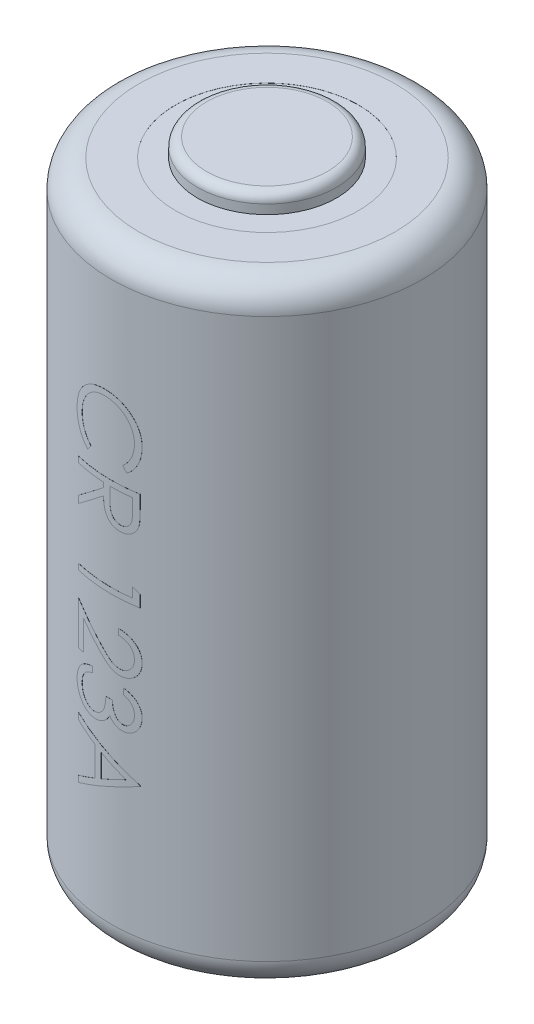
from build123d import *

# Parameters (mm, degrees)
SKIZZE1_R                            = 8.5
AUFSATZ_LINEAR_AUSTRAGEN1_DEPTH      = 33.5
SKIZZE2_R                            = 3.799988553
AUFSATZ_LINEAR_AUSTRAGEN2_DEPTH      = 1
VERRUNDUNG1_R                        = 1.5
VERRUNDUNG2_R                        = 0.5
SKIZZE3_R                            = 5
SKIZZE3_R_2                          = 3.799988553
SCHNITT_LINEAR_AUSTRAGEN1_DEPTH      = 0.005
AUFSATZ_LINEAR_AUSTRAGEN3_REACH      = 38.534
AUFSATZ_LINEAR_AUSTRAGEN3_END_RADIUS = 8.505


with BuildPart() as part:
    # Skizze1 → Aufsatz-Linear austragen1 (new body)
    with BuildSketch(Plane(origin=(0, 0, 0), x_dir=(1, 0, 0), z_dir=(0, 1, 0))):
        with Locations(Location((0, 0, 0), (0, 0, 270))):
            Circle(SKIZZE1_R)
    extrude(amount=AUFSATZ_LINEAR_AUSTRAGEN1_DEPTH)

    # Skizze2 → Aufsatz-Linear austragen2 (add)
    with BuildSketch(Plane(origin=(0, 33.5, 0), x_dir=(1, 0, 0), z_dir=(0, 1, 0))):
        with Locations(Location((0, 0, 0), (0, 0, 270))):
            Circle(SKIZZE2_R)
    extrude(amount=AUFSATZ_LINEAR_AUSTRAGEN2_DEPTH)

    # Verrundung1
    verrundung1_edges = [part.edges().sort_by_distance(p)[0] for p in [
        (0, 0, -8.5),
        (0, 33.5, -8.5),
    ]]
    fillet(verrundung1_edges, radius=VERRUNDUNG1_R)

    # Verrundung2
    verrundung2_edges = [part.edges().sort_by_distance(p)[0] for p in [
        (0, 34.5, -3.799988553),
    ]]
    fillet(verrundung2_edges, radius=VERRUNDUNG2_R)

    # Skizze3 → Schnitt-Linear austragen1 (cut)
    with BuildSketch(Plane(origin=(0, 33.5, 0), x_dir=(1, 0, 0), z_dir=(0, 1, 0))):
        with Locations(Location((0, 0, 0), (0, 0, 270))):
            Circle(SKIZZE3_R)
        with Locations(Location((0, 0, 0), (0, 0, 270))):
            Circle(SKIZZE3_R_2, mode=Mode.SUBTRACT)
    extrude(amount=-SCHNITT_LINEAR_AUSTRAGEN1_DEPTH, mode=Mode.SUBTRACT)

    # Aufsatz-Linear austragen3: up to this cylinder (the profile starts inside it)
    aufsatz_linear_austragen3_end = Plane(origin=(0, 15.6548225, 0), z_dir=(0, -1, 0)) * Cylinder(AUFSATZ_LINEAR_AUSTRAGEN3_END_RADIUS, 110.548259, mode=Mode.PRIVATE)
    # Skizze4 → Aufsatz-Linear austragen3 (add, up to the surface)
    with BuildSketch(Plane.XY, mode=Mode.PRIVATE) as aufsatz_linear_austragen3_sk1:
        with BuildLine():
            Line((0.812137548, 23.222042681), (0.60180101, 23.496882424))
            add(Edge.make_bspline(
                [(0.60180101, 23.496882424), (0.62516698, 23.516488313), (0.671583895, 23.555435759), (0.73676344, 23.618094962), (0.797828701, 23.683396605), (0.855070581, 23.751315726), (0.906487347, 23.823074845), (0.95475845, 23.896935644), (0.998026188, 23.974133689), (1.050489174, 24.080885424), (1.105235329, 24.220533272), (1.15113856, 24.396328111), (1.180359736, 24.57983921), (1.183524577, 24.705036809), (1.185134343, 24.76871736)],
                knots=[0, 0, 0, 0, 0.757959112, 1.505699292, 2.245454638, 2.979532153, 3.711538275, 4.438200793, 5.171680507, 5.909471876, 7.393775596, 8.890124382, 10.418191784, 12, 12, 12, 12], degree=3))
            add(Edge.make_bspline(
                [(1.185134343, 24.76871736), (1.184728558, 24.803800233), (1.183920753, 24.873640377), (1.173338528, 24.977295144), (1.158293792, 25.079210677), (1.136513413, 25.179007988), (1.108157335, 25.276488925), (1.074903224, 25.372395725), (1.033521858, 25.465598861), (0.987821664, 25.55722001), (0.936188844, 25.644995169), (0.87988858, 25.728063146), (0.819473451, 25.806044444), (0.755099407, 25.87915515), (0.685966407, 25.946593449), (0.612887721, 26.009440138), (0.534983754, 26.066562574), (0.453715531, 26.119364439), (0.368963602, 26.166348655), (0.281261128, 26.206921801), (0.190943428, 26.24169636), (0.097825479, 26.269467711), (0.002273724, 26.291372711), (-0.09591462, 26.30650568), (-0.196548965, 26.316992708), (-0.264758187, 26.317793081), (-0.299140497, 26.318196527)],
                knots=[0, 0, 0, 0, 1.055000685, 2.100209969, 3.131349012, 4.153242145, 5.170189196, 6.184191144, 7.204341339, 8.235672124, 9.263040994, 10.265373269, 11.252624173, 12.22887325, 13.193405896, 14.155809299, 15.126090485, 16.097288279, 17.069732292, 18.038585918, 19.002221264, 19.978698174, 20.959418239, 21.948869816, 22.966084182, 24, 24, 24, 24], degree=3))
            add(Edge.make_bspline(
                [(-0.299140497, 26.318196527), (-0.350871816, 26.316934708), (-0.452439401, 26.314457293), (-0.601210012, 26.292408959), (-0.743730686, 26.258903868), (-0.879110528, 26.208688291), (-1.009018886, 26.146769241), (-1.131257739, 26.068528629), (-1.247674304, 25.977912092), (-1.355517252, 25.873637672), (-1.454030977, 25.759231856), (-1.540781558, 25.636483945), (-1.613096441, 25.505699657), (-1.673272387, 25.368323027), (-1.719529115, 25.223296913), (-1.752093239, 25.07088211), (-1.773335419, 24.911410115), (-1.775369107, 24.802440715), (-1.776404118, 24.746982584)],
                knots=[0, 0, 0, 0, 1.029171465, 2.020641659, 2.987623507, 3.938342917, 4.889210282, 5.84687017, 6.821220943, 7.821438502, 8.827599549, 9.822697543, 10.807740252, 11.797342354, 12.80366471, 13.83203677, 14.896651826, 16, 16, 16, 16], degree=3))
            add(Edge.make_bspline(
                [(-1.776404118, 24.746982584), (-1.774715339, 24.685879895), (-1.771391416, 24.565615187), (-1.743232167, 24.38924716), (-1.697574249, 24.220411395), (-1.633676327, 24.059098808), (-1.550611039, 23.905764162), (-1.449913161, 23.760167502), (-1.330624829, 23.622185931), (-1.2395417, 23.539214649), (-1.193070785, 23.496882424)],
                knots=[0, 0, 0, 0, 1.028121516, 2.023589091, 2.998037872, 3.967518031, 4.937445131, 5.927275754, 6.942489185, 8, 8, 8, 8], degree=3))
            Line((-1.193070785, 23.496882424), (-1.401303958, 23.222042681))
            add(Edge.make_bspline(
                [(-1.401303958, 23.222042681), (-1.429842459, 23.244160761), (-1.486782762, 23.288290978), (-1.567053749, 23.35974943), (-1.642560487, 23.435025101), (-1.712678052, 23.514686863), (-1.778870221, 23.597781962), (-1.838917955, 23.685774076), (-1.894650403, 23.77714341), (-1.945006838, 23.87242193), (-1.990156908, 23.971296824), (-2.028273845, 24.073665195), (-2.061580939, 24.178659772), (-2.088801157, 24.286333431), (-2.110080876, 24.397045881), (-2.12429818, 24.510417263), (-2.134040734, 24.626686893), (-2.134928563, 24.705128347), (-2.135378477, 24.744879219)],
                knots=[0, 0, 0, 0, 0.986756325, 1.968786143, 2.935506311, 3.899499537, 4.868307269, 5.8376204, 6.809456583, 7.792545619, 8.781780509, 9.778496008, 10.776623214, 11.79151764, 12.812666265, 13.856269958, 14.913646641, 16, 16, 16, 16], degree=3))
            add(Edge.make_bspline(
                [(-2.135378477, 24.744879219), (-2.135116485, 24.782522886), (-2.134598427, 24.856958576), (-2.12620626, 24.966857328), (-2.114756523, 25.073846909), (-2.097516392, 25.177621535), (-2.077172051, 25.27874751), (-2.049900795, 25.376308094), (-2.019351628, 25.471263304), (-1.983446642, 25.563231645), (-1.942930459, 25.652291345), (-1.8971389, 25.738155156), (-1.846457035, 25.820783589), (-1.792002025, 25.90098901), (-1.732024723, 25.977586593), (-1.667358089, 26.051240119), (-1.598220078, 26.122362595), (-1.548365225, 26.16636528), (-1.52329915, 26.188488995)],
                knots=[0, 0, 0, 0, 1.114604814, 2.203992996, 3.262667896, 4.300477797, 5.318619304, 6.316056647, 7.298880507, 8.271930387, 9.238335007, 10.195173496, 11.151986948, 12.108099108, 13.064862484, 14.031167946, 15.010108607, 16, 16, 16, 16], degree=3))
            add(Edge.make_bspline(
                [(-1.52329915, 26.188488995), (-1.479757961, 26.223924638), (-1.393201251, 26.294368115), (-1.25291527, 26.384493799), (-1.106447061, 26.461641354), (-0.953027132, 26.524017275), (-0.792999745, 26.572780008), (-0.62628423, 26.606561203), (-0.453036288, 26.628512807), (-0.3351995, 26.631023096), (-0.275302356, 26.632299091)],
                knots=[0, 0, 0, 0, 0.994628077, 1.977248131, 2.950237994, 3.925870899, 4.908910175, 5.911660606, 6.938484602, 8, 8, 8, 8], degree=3))
            add(Edge.make_bspline(
                [(-0.275302356, 26.632299091), (-0.212349536, 26.630736941), (-0.088493793, 26.62766351), (0.093317753, 26.601766994), (0.267255421, 26.559602465), (0.43398848, 26.501541626), (0.592562947, 26.424943857), (0.74364855, 26.332216062), (0.887121922, 26.222452515), (1.021148744, 26.097031743), (1.143684832, 25.95945716), (1.251491889, 25.812140241), (1.34120918, 25.655357794), (1.416205403, 25.490840076), (1.47384985, 25.317354359), (1.514203041, 25.135270999), (1.539320156, 24.944932082), (1.542495364, 24.815069657), (1.544108702, 24.74908595)],
                knots=[0, 0, 0, 0, 1.032901378, 2.032168977, 3.007206631, 3.966850309, 4.924221947, 5.891988639, 6.871730993, 7.884084801, 8.900290346, 9.89161143, 10.874607481, 11.860025555, 12.854717796, 13.869097222, 14.917278314, 16, 16, 16, 16], degree=3))
            add(Edge.make_bspline(
                [(1.544108702, 24.74908595), (1.543626924, 24.708871399), (1.542673293, 24.629270746), (1.533361929, 24.511519236), (1.517867523, 24.39687271), (1.49663914, 24.285053911), (1.470620258, 24.175657363), (1.436559531, 24.06980539), (1.397006677, 23.966921591), (1.352614272, 23.86692891), (1.301863581, 23.770915237), (1.246743012, 23.678898047), (1.185980195, 23.591987357), (1.121583953, 23.508548372), (1.051145443, 23.430459568), (0.97695855, 23.355490747), (0.896821888, 23.286231616), (0.840417335, 23.24347816), (0.812137548, 23.222042681)],
                knots=[0, 0, 0, 0, 1.096705196, 2.170817488, 3.219277236, 4.250701065, 5.274195539, 6.284202015, 7.28098643, 8.279664616, 9.266225751, 10.241373748, 11.203306326, 12.157093976, 13.114198862, 14.069774147, 15.032234603, 16, 16, 16, 16], degree=3))
        make_face()
    aufsatz_linear_austragen3_tool1 = extrude(aufsatz_linear_austragen3_sk1.sketch, amount=AUFSATZ_LINEAR_AUSTRAGEN3_REACH, mode=Mode.PRIVATE) & aufsatz_linear_austragen3_end
    add(aufsatz_linear_austragen3_tool1.solids().sort_by_distance((0.746809, 23.389952, 0))[0])
    # Skizze4 → Aufsatz-Linear austragen3 (add, up to the surface)
    with BuildSketch(Plane.XY, mode=Mode.PRIVATE) as aufsatz_linear_austragen3_sk2:
        with BuildLine():
            Line((1.454365112, 22.504093963), (1.454365112, 21.80367329))
            add(Edge.make_bspline(
                [(1.454365112, 21.80367329), (1.454209526, 21.756932161), (1.453910784, 21.667184017), (1.452245021, 21.538610746), (1.447470666, 21.421783649), (1.443362082, 21.31676381), (1.435870141, 21.223553155), (1.428709494, 21.141865864), (1.419335833, 21.072078167), (1.41063041, 21.029832315), (1.40668883, 21.01070454)],
                knots=[0, 0, 0, 0, 1.410062039, 2.707475311, 3.878576406, 4.937260626, 5.877586885, 6.699081471, 7.410979367, 8, 8, 8, 8], degree=3))
            add(Edge.make_bspline(
                [(1.40668883, 21.01070454), (1.400362783, 20.985097464), (1.387845639, 20.934429582), (1.361375626, 20.86148606), (1.330794417, 20.791947595), (1.294596859, 20.726075144), (1.253414315, 20.663862597), (1.207006171, 20.605403103), (1.155136087, 20.551030892), (1.099128607, 20.500327595), (1.038495049, 20.454366688), (0.97411868, 20.414593537), (0.906402136, 20.380535988), (0.835109603, 20.353346822), (0.760843742, 20.331473971), (0.682956073, 20.316046319), (0.601794786, 20.306795522), (0.54643692, 20.305853612), (0.518367516, 20.305376014)],
                knots=[0, 0, 0, 0, 1.02737288, 2.032829108, 3.019628684, 3.985738875, 4.958353778, 5.924249254, 6.890702889, 7.883913451, 8.865824512, 9.85161466, 10.829249435, 11.81541824, 12.821369441, 13.843154991, 14.906364023, 16, 16, 16, 16], degree=3))
            add(Edge.make_bspline(
                [(0.518367516, 20.305376014), (0.471732358, 20.306844974), (0.380735085, 20.309711295), (0.248674954, 20.336436932), (0.125482898, 20.380211504), (0.011330359, 20.440541967), (-0.091617661, 20.517334891), (-0.181734433, 20.609622523), (-0.257842153, 20.716933557), (-0.310058757, 20.817302112), (-0.343657158, 20.906004496), (-0.36741579, 20.979244166), (-0.385462767, 21.05919693), (-0.401864947, 21.144715744), (-0.414381128, 21.236461164), (-0.423269996, 21.334248438), (-0.428985605, 21.438322137), (-0.42982068, 21.509661899), (-0.430250272, 21.546361591)],
                knots=[0, 0, 0, 0, 1.260402266, 2.459371274, 3.627181936, 4.786749125, 5.93865593, 7.087644312, 8.261344208, 9.485713728, 10.136162886, 10.825977872, 11.566646758, 12.35154167, 13.181268117, 14.0701832, 15.007234106, 16, 16, 16, 16], degree=3))
            Line((-0.430250272, 21.546361591), (-2.045634888, 20.260504219))
            Line((-2.045634888, 20.260504219), (-2.045634888, 20.648925693))
            Line((-2.045634888, 20.648925693), (-0.430250272, 21.934783065))
            Line((-0.430250272, 21.934783065), (-0.430250272, 22.189991399))
            Line((-0.430250272, 22.189991399), (-2.045634888, 22.189991399))
            Line((-2.045634888, 22.189991399), (-2.045634888, 22.504093963))
            Line((-2.045634888, 22.504093963), (1.454365112, 22.504093963))
        make_face()
        with BuildLine():
            Line((1.095390753, 22.189991399), (-0.071275913, 22.189991399))
            Line((-0.071275913, 22.189991399), (-0.076183766, 21.549166078))
            add(Edge.make_bspline(
                [(-0.076183766, 21.549166078), (-0.076197002, 21.519246039), (-0.076222659, 21.461252482), (-0.072228884, 21.377351816), (-0.067685561, 21.29923171), (-0.06073623, 21.227190939), (-0.05178011, 21.161197426), (-0.040577283, 21.101283808), (-0.027524707, 21.047353424), (-0.007325244, 20.984452072), (0.024695395, 20.914234557), (0.071203548, 20.837828514), (0.130079173, 20.77298334), (0.196332539, 20.717074233), (0.270674926, 20.67400998), (0.349806555, 20.64266676), (0.433044259, 20.622997142), (0.490216103, 20.620658703), (0.519068638, 20.619478578)],
                knots=[0, 0, 0, 0, 1.14660753, 2.222451964, 3.218720504, 4.145691244, 4.995719623, 5.770487122, 6.480909919, 7.121111896, 8.299844659, 9.430703709, 10.534634535, 11.641396424, 12.741395289, 13.810956493, 14.895269934, 16, 16, 16, 16], degree=3))
            add(Edge.make_bspline(
                [(0.519068638, 20.619478578), (0.547223017, 20.62066233), (0.603014723, 20.623008096), (0.68446816, 20.64270487), (0.761895021, 20.674512282), (0.8338195, 20.719113634), (0.899651492, 20.773007527), (0.955200409, 20.837014539), (1.00171939, 20.907911198), (1.031229533, 20.97422142), (1.049358083, 21.033449576), (1.062099247, 21.084881682), (1.072422096, 21.143216452), (1.080447915, 21.208314084), (1.087670236, 21.280056805), (1.092352997, 21.358641061), (1.095183259, 21.443976103), (1.095319979, 21.503123286), (1.095390753, 21.533741399)],
                knots=[0, 0, 0, 0, 1.100801541, 2.181386982, 3.260112282, 4.364594493, 5.481957178, 6.577424609, 7.668452592, 8.790448866, 9.403819393, 10.091598921, 10.863153553, 11.720938239, 12.658472417, 13.685008818, 14.801622349, 16, 16, 16, 16], degree=3))
            Line((1.095390753, 21.533741399), (1.095390753, 22.189991399))
        make_face(mode=Mode.SUBTRACT)
    aufsatz_linear_austragen3_tool2 = extrude(aufsatz_linear_austragen3_sk2.sketch, amount=AUFSATZ_LINEAR_AUSTRAGEN3_REACH, mode=Mode.PRIVATE) & aufsatz_linear_austragen3_end
    add(aufsatz_linear_austragen3_tool2.solids().sort_by_distance((-0.10468, 21.567098, 0))[0])
    # Skizze4 → Aufsatz-Linear austragen3 (add, up to the surface)
    with BuildSketch(Plane.XY, mode=Mode.PRIVATE) as aufsatz_linear_austragen3_sk3:
        Polygon((1.454365112, 17.766613995), (1.454365112, 17.119478578), (-2.045634888, 17.119478578), (-2.045634888, 17.433581142), (1.095390753, 17.433581142), (1.095390753, 17.972042681), align=None)
    aufsatz_linear_austragen3_tool3 = extrude(aufsatz_linear_austragen3_sk3.sketch, amount=AUFSATZ_LINEAR_AUSTRAGEN3_REACH, mode=Mode.PRIVATE) & aufsatz_linear_austragen3_end
    add(aufsatz_linear_austragen3_tool3.solids().sort_by_distance((-0.101766, 17.323734, 0))[0])
    # Skizze4 → Aufsatz-Linear austragen3 (add, up to the surface)
    with BuildSketch(Plane.XY, mode=Mode.PRIVATE) as aufsatz_linear_austragen3_sk4:
        with BuildLine():
            Line((0.377442036, 15.369478578), (0.377442036, 15.683581142))
            add(Edge.make_bspline(
                [(0.377442036, 15.683581142), (0.419113129, 15.681534338), (0.500954047, 15.677514468), (0.620275047, 15.658681248), (0.734340365, 15.631758216), (0.842172101, 15.593601998), (0.945058395, 15.546482403), (1.041633037, 15.488794384), (1.132854518, 15.421767754), (1.216995714, 15.345525477), (1.293911286, 15.26279558), (1.361034701, 15.174073744), (1.417098552, 15.080271861), (1.464221512, 14.982203528), (1.499550068, 14.878734557), (1.52577479, 14.770853994), (1.541550295, 14.658074232), (1.543246197, 14.581234296), (1.544108702, 14.54215486)],
                knots=[0, 0, 0, 0, 1.100776268, 2.161895295, 3.184016182, 4.190939212, 5.176500551, 6.166955529, 7.155448256, 8.160289653, 9.16017456, 10.133824356, 11.091467644, 12.04088621, 13.000931625, 13.972173743, 14.968683325, 16, 16, 16, 16], degree=3))
            add(Edge.make_bspline(
                [(1.544108702, 14.54215486), (1.543210246, 14.503776786), (1.541444811, 14.428365241), (1.526283782, 14.318303227), (1.50253819, 14.213525932), (1.469222774, 14.114238166), (1.424438346, 14.021232101), (1.370640808, 13.933809057), (1.308420976, 13.850928246), (1.235167163, 13.776321462), (1.156964778, 13.707813383), (1.073476875, 13.648711128), (0.987247589, 13.598097965), (0.897619387, 13.555910285), (0.803748359, 13.524854146), (0.707001156, 13.501275938), (0.606376345, 13.487948524), (0.53826979, 13.4859031), (0.503643959, 13.484863193)],
                knots=[0, 0, 0, 0, 1.111607364, 2.184268762, 3.212621178, 4.221274766, 5.211760367, 6.196651075, 7.1921475, 8.207485113, 9.220403448, 10.201281604, 11.166441695, 12.114753415, 13.065576456, 14.026450734, 14.996634279, 16, 16, 16, 16], degree=3))
            add(Edge.make_bspline(
                [(0.503643959, 13.484863193), (0.454896124, 13.486556456), (0.35825591, 13.489913268), (0.216241048, 13.518627644), (0.078647629, 13.563474155), (-0.032089674, 13.617471512), (-0.121323167, 13.671943956), (-0.194791872, 13.721031464), (-0.273897341, 13.778496275), (-0.358374678, 13.845174773), (-0.448885583, 13.919687645), (-0.545375379, 14.002709808), (-0.646847148, 14.09483329), (-0.71615275, 14.159491791), (-0.752065176, 14.192996206)],
                knots=[0, 0, 0, 0, 1.184426356, 2.348067706, 3.509069118, 4.696110526, 5.333549288, 6.050745305, 6.844228056, 7.710549037, 8.667450064, 9.695053472, 10.805634456, 12, 12, 12, 12], degree=3))
            Line((-0.752065176, 14.192996206), (-1.686660529, 15.068697328))
            Line((-1.686660529, 15.068697328), (-1.686660529, 13.439991399))
            Line((-1.686660529, 13.439991399), (-2.045634888, 13.439991399))
            Line((-2.045634888, 13.439991399), (-2.045634888, 15.818196527))
            Line((-2.045634888, 15.818196527), (-0.597117259, 14.460824732))
            add(Edge.make_bspline(
                [(-0.597117259, 14.460824732), (-0.562620834, 14.427774505), (-0.496360262, 14.364291784), (-0.399592547, 14.27453999), (-0.309925211, 14.193798781), (-0.226960917, 14.122014596), (-0.151169996, 14.059128372), (-0.081958491, 14.005341317), (-0.019920356, 13.960415702), (0.052959451, 13.912803911), (0.142046982, 13.86740291), (0.250368976, 13.827500075), (0.362124569, 13.803343441), (0.43762282, 13.800430827), (0.475599087, 13.798965758)],
                knots=[0, 0, 0, 0, 1.329530082, 2.553755191, 3.672934919, 4.687409497, 5.60679272, 6.413407421, 7.126401618, 7.737995624, 8.834647426, 9.90044882, 10.943907757, 12, 12, 12, 12], degree=3))
            add(Edge.make_bspline(
                [(0.475599087, 13.798965758), (0.499483124, 13.79959497), (0.546553976, 13.800835025), (0.61552187, 13.811986421), (0.6823074, 13.828370035), (0.746084812, 13.853622246), (0.808108484, 13.883961846), (0.866492703, 13.922722924), (0.923227646, 13.967016657), (0.97636792, 14.018395214), (1.025052662, 14.074799323), (1.068175824, 14.134395508), (1.104215176, 14.197445108), (1.133758608, 14.263685365), (1.156934007, 14.332930798), (1.172992582, 14.405315553), (1.183075067, 14.480639566), (1.184439238, 14.532073062), (1.185134343, 14.558280661)],
                knots=[0, 0, 0, 0, 0.991504627, 1.954065223, 2.895985987, 3.842598665, 4.797835564, 5.759220273, 6.74786863, 7.784730864, 8.824135544, 9.839918996, 10.835834653, 11.835434876, 12.84861661, 13.863796685, 14.911511676, 16, 16, 16, 16], degree=3))
            add(Edge.make_bspline(
                [(1.185134343, 14.558280661), (1.184419527, 14.585651616), (1.183015747, 14.63940365), (1.173190015, 14.71832096), (1.156255342, 14.793613011), (1.133038264, 14.865432216), (1.103807778, 14.933847773), (1.066697477, 14.998241068), (1.023156282, 15.059199991), (0.973521696, 15.116612581), (0.917999529, 15.169365744), (0.856868762, 15.216689618), (0.789731746, 15.257051879), (0.718104905, 15.292831207), (0.640083769, 15.320207689), (0.55755897, 15.343608841), (0.469358029, 15.360608049), (0.408589577, 15.366472625), (0.377442036, 15.369478578)],
                knots=[0, 0, 0, 0, 1.031212865, 2.025131798, 2.990757446, 3.934781266, 4.865570067, 5.788494791, 6.729227313, 7.684356718, 8.643577152, 9.610526866, 10.590658432, 11.59095419, 12.621640561, 13.700587263, 14.82141059, 16, 16, 16, 16], degree=3))
        make_face()
    aufsatz_linear_austragen3_tool4 = extrude(aufsatz_linear_austragen3_sk4.sketch, amount=AUFSATZ_LINEAR_AUSTRAGEN3_REACH, mode=Mode.PRIVATE) & aufsatz_linear_austragen3_end
    add(aufsatz_linear_austragen3_tool4.solids().sort_by_distance((0.420503, 15.52653, 0))[0])
    # Skizze4 → Aufsatz-Linear austragen3 (add, up to the surface)
    with BuildSketch(Plane.XY, mode=Mode.PRIVATE) as aufsatz_linear_austragen3_sk5:
        with BuildLine():
            Line((0.646672805, 12.677170886), (0.646672805, 12.99127345))
            add(Edge.make_bspline(
                [(0.646672805, 12.99127345), (0.681905289, 12.982763899), (0.750781913, 12.966128424), (0.849189174, 12.93143085), (0.942312695, 12.893631595), (1.028408769, 12.84824249), (1.109207672, 12.798733736), (1.182876796, 12.742011015), (1.251289762, 12.680691292), (1.312002999, 12.612866343), (1.366980728, 12.541737681), (1.413855786, 12.466303061), (1.454179939, 12.388080168), (1.487400171, 12.306527035), (1.512425694, 12.221400863), (1.5305825, 12.13347124), (1.542373614, 12.04250774), (1.543524377, 11.980760149), (1.544108702, 11.949406463)],
                knots=[0, 0, 0, 0, 1.162005537, 2.271625781, 3.343758855, 4.383309926, 5.390229558, 6.379919256, 7.361854164, 8.333198761, 9.295911338, 10.242430842, 11.177959212, 12.116337295, 13.062827104, 14.020064771, 14.994644689, 16, 16, 16, 16], degree=3))
            add(Edge.make_bspline(
                [(1.544108702, 11.949406463), (1.542729472, 11.903723721), (1.540001096, 11.81335471), (1.51508666, 11.680591663), (1.475661528, 11.552564844), (1.4211878, 11.430675596), (1.354000487, 11.317457163), (1.27403575, 11.216720976), (1.182836449, 11.129832466), (1.082103885, 11.056938088), (0.974448375, 10.999863089), (0.863648218, 10.957776715), (0.749966247, 10.932155034), (0.673208968, 10.928834478), (0.634753734, 10.927170886)],
                knots=[0, 0, 0, 0, 1.083050992, 2.142477498, 3.193116406, 4.255571735, 5.30263384, 6.308962982, 7.297363603, 8.282367274, 9.249857812, 10.179914175, 11.08814088, 12, 12, 12, 12], degree=3))
            add(Edge.make_bspline(
                [(0.634753734, 10.927170886), (0.59774694, 10.928334477), (0.525330385, 10.930611444), (0.419608888, 10.949945149), (0.319967288, 10.982481412), (0.225986126, 11.027551175), (0.138261286, 11.085892725), (0.056595395, 11.156565422), (-0.019373763, 11.240068084), (-0.062893236, 11.303347022), (-0.085298349, 11.335924892)],
                knots=[0, 0, 0, 0, 1.024540389, 2.004866551, 2.965041327, 3.920577974, 4.882998113, 5.874504559, 6.905732034, 8, 8, 8, 8], degree=3))
            add(Edge.make_bspline(
                [(-0.085298349, 11.335924892), (-0.103276521, 11.298693138), (-0.138896478, 11.224926263), (-0.208752236, 11.124375734), (-0.289408583, 11.033097858), (-0.352351236, 10.982194139), (-0.383976234, 10.956618001)],
                knots=[0, 0, 0, 0, 1.015518401, 2.012035669, 3.001164323, 4, 4, 4, 4], degree=3))
            add(Edge.make_bspline(
                [(-0.383976234, 10.956618001), (-0.407031528, 10.939769803), (-0.45276457, 10.906349309), (-0.526336896, 10.865213928), (-0.600481127, 10.827469445), (-0.67811252, 10.799690597), (-0.756737418, 10.775718552), (-0.838039493, 10.759945745), (-0.921246307, 10.749820234), (-0.977563012, 10.748398405), (-1.005871266, 10.747683706)],
                knots=[0, 0, 0, 0, 1.02516404, 2.033540309, 3.025129118, 4.011046665, 4.991655828, 5.976607087, 6.982917762, 8, 8, 8, 8], degree=3))
            add(Edge.make_bspline(
                [(-1.005871266, 10.747683706), (-1.054879038, 10.749482171), (-1.152663951, 10.753070638), (-1.297167906, 10.78501544), (-1.438178645, 10.834824184), (-1.573606849, 10.904320052), (-1.700053427, 10.990304698), (-1.812675456, 11.093167704), (-1.910134371, 11.210408488), (-1.991301019, 11.341259731), (-2.056230835, 11.482964416), (-2.101285041, 11.634543394), (-2.130631923, 11.793792526), (-2.13377867, 11.90299995), (-2.135378477, 11.958521046)],
                knots=[0, 0, 0, 0, 0.95570045, 1.906903359, 2.87519758, 3.868912786, 4.869932978, 5.851730567, 6.836639976, 7.83677598, 8.849487602, 9.869908895, 10.917060885, 12, 12, 12, 12], degree=3))
            add(Edge.make_bspline(
                [(-2.135378477, 11.958521046), (-2.134510264, 11.995940346), (-2.13280191, 12.069569051), (-2.121123309, 12.17781255), (-2.099793303, 12.281134249), (-2.071089998, 12.379673847), (-2.034698256, 12.473518883), (-1.989379558, 12.562382989), (-1.936068056, 12.646812882), (-1.874134468, 12.726011833), (-1.804853128, 12.799970401), (-1.726994118, 12.866723125), (-1.641996714, 12.927382918), (-1.548873658, 12.980325557), (-1.448828401, 13.027962509), (-1.340579903, 13.067143466), (-1.225095881, 13.101629035), (-1.14461814, 13.117662499), (-1.103327195, 13.125888834)],
                knots=[0, 0, 0, 0, 1.048658725, 2.063410685, 3.046034179, 4.001477787, 4.936774919, 5.862367409, 6.792675028, 7.730719943, 8.675894397, 9.627829632, 10.600096036, 11.597688215, 12.626045268, 13.701542398, 14.82072376, 16, 16, 16, 16], degree=3))
            Line((-1.103327195, 13.125888834), (-1.103327195, 12.81178627))
            add(Edge.make_bspline(
                [(-1.103327195, 12.81178627), (-1.130276209, 12.803602979), (-1.18269438, 12.787685766), (-1.258134686, 12.760591468), (-1.327292739, 12.729723196), (-1.390675861, 12.696608638), (-1.448908263, 12.661830191), (-1.500450133, 12.622915266), (-1.547565335, 12.582746121), (-1.574109947, 12.552466768), (-1.587101234, 12.537647649)],
                knots=[0, 0, 0, 0, 1.198163088, 2.33053128, 3.407730985, 4.417276592, 5.372219308, 6.28897303, 7.162600585, 8, 8, 8, 8], degree=3))
            add(Edge.make_bspline(
                [(-1.587101234, 12.537647649), (-1.602209568, 12.518051072), (-1.632379599, 12.478918409), (-1.670881228, 12.415150178), (-1.704242253, 12.348085292), (-1.729725949, 12.276270618), (-1.75130361, 12.201255847), (-1.765424129, 12.121828482), (-1.7751123, 12.038689265), (-1.775967232, 11.981921501), (-1.776404118, 11.952912072)],
                knots=[0, 0, 0, 0, 0.946170439, 1.889420265, 2.845303464, 3.807233317, 4.801018734, 5.828864929, 6.890507805, 8, 8, 8, 8], degree=3))
            add(Edge.make_bspline(
                [(-1.776404118, 11.952912072), (-1.775789215, 11.920158126), (-1.774586824, 11.856110612), (-1.763497123, 11.762661947), (-1.747416711, 11.673732367), (-1.72226382, 11.590229398), (-1.692088772, 11.51101677), (-1.652584097, 11.437862737), (-1.607969952, 11.368616662), (-1.556075121, 11.305307134), (-1.499982427, 11.248230498), (-1.440473076, 11.198909979), (-1.379392248, 11.156192769), (-1.315315048, 11.12185526), (-1.248870024, 11.09469268), (-1.179808471, 11.07621269), (-1.10871193, 11.06336032), (-1.060382863, 11.062313824), (-1.036019503, 11.06178627)],
                knots=[0, 0, 0, 0, 1.216990249, 2.379719373, 3.493992396, 4.571561497, 5.616923107, 6.638958652, 7.655775068, 8.674704564, 9.676001865, 10.625896028, 11.54399481, 12.441854662, 13.322657739, 14.20572845, 15.095482574, 16, 16, 16, 16], degree=3))
            add(Edge.make_bspline(
                [(-1.036019503, 11.06178627), (-1.003408127, 11.063316545), (-0.938347645, 11.066369479), (-0.842630623, 11.089678465), (-0.750405058, 11.128015742), (-0.663257703, 11.181694473), (-0.582449544, 11.247006418), (-0.5106309, 11.323319362), (-0.450774202, 11.410820499), (-0.409571095, 11.491873175), (-0.382110957, 11.56384018), (-0.362856423, 11.625305719), (-0.347464689, 11.694179135), (-0.332576248, 11.769633617), (-0.320094723, 11.851987395), (-0.309640957, 11.941314664), (-0.301289441, 12.03765136), (-0.297557841, 12.104342392), (-0.295634888, 12.138709347)],
                knots=[0, 0, 0, 0, 1.070481957, 2.135637345, 3.216366529, 4.339485895, 5.485746587, 6.620975969, 7.768829582, 8.956804399, 9.598399438, 10.297751078, 11.070570279, 11.915248466, 12.824061284, 13.805856426, 14.869322739, 16, 16, 16, 16], degree=3))
            Line((-0.295634888, 12.138709347), (0.063339471, 12.138709347))
            add(Edge.make_bspline(
                [(0.063339471, 12.138709347), (0.064077479, 12.095409378), (0.065523055, 12.010595376), (0.082885965, 11.886684224), (0.107174391, 11.768053941), (0.143518792, 11.657412399), (0.187142446, 11.55689539), (0.236331302, 11.469210041), (0.292060068, 11.39643446), (0.353597359, 11.338386824), (0.420367534, 11.29578192), (0.489231031, 11.26380272), (0.561790075, 11.245055217), (0.611280059, 11.242538478), (0.636155978, 11.24127345)],
                knots=[0, 0, 0, 0, 1.321708579, 2.588902423, 3.815526512, 5.016621128, 6.138757764, 7.158873101, 8.079948563, 8.928590313, 9.728601868, 10.489025425, 11.240515403, 12, 12, 12, 12], degree=3))
            add(Edge.make_bspline(
                [(0.636155978, 11.24127345), (0.654433767, 11.241687813), (0.690796561, 11.242512168), (0.743920985, 11.252910153), (0.795424338, 11.268531552), (0.845072928, 11.290021404), (0.892578572, 11.318732768), (0.937999549, 11.35319597), (0.982097069, 11.393427642), (1.022761452, 11.44047924), (1.061118378, 11.491417612), (1.094276514, 11.546722058), (1.122381328, 11.605172769), (1.145601896, 11.666823496), (1.163058137, 11.731921209), (1.175594832, 11.800147155), (1.183432249, 11.871635009), (1.184560698, 11.920406717), (1.185134343, 11.945199732)],
                knots=[0, 0, 0, 0, 0.884317272, 1.759307272, 2.611736065, 3.488921043, 4.37244062, 5.294096728, 6.247679003, 7.258495569, 8.302441962, 9.333537773, 10.376747089, 11.440883505, 12.520330301, 13.637364711, 14.798958396, 16, 16, 16, 16], degree=3))
            add(Edge.make_bspline(
                [(1.185134343, 11.945199732), (1.18374568, 11.985052717), (1.181033298, 12.062894865), (1.157192682, 12.175091434), (1.119419683, 12.279285662), (1.0738089, 12.358660645), (1.028940108, 12.41737339), (0.990339486, 12.460133361), (0.946574287, 12.501358353), (0.89644408, 12.539430661), (0.841672641, 12.576631657), (0.781958309, 12.612606127), (0.716449737, 12.646198572), (0.67038222, 12.666646842), (0.646672805, 12.677170886)],
                knots=[0, 0, 0, 0, 1.4727372, 2.876598283, 4.222346151, 5.558423782, 6.24313385, 6.953189256, 7.68715613, 8.463578749, 9.278833271, 10.135787152, 11.040551781, 12, 12, 12, 12], degree=3))
        make_face()
    aufsatz_linear_austragen3_tool5 = extrude(aufsatz_linear_austragen3_sk5.sketch, amount=AUFSATZ_LINEAR_AUSTRAGEN3_REACH, mode=Mode.PRIVATE) & aufsatz_linear_austragen3_end
    add(aufsatz_linear_austragen3_tool5.solids().sort_by_distance((-0.324624, 11.74078, 0))[0])
    # Skizze4 → Aufsatz-Linear austragen3 (add, up to the surface)
    with BuildSketch(Plane.XY, mode=Mode.PRIVATE) as aufsatz_linear_austragen3_sk6:
        Polygon((1.454365112, 8.683581142), (-2.045634888, 7.068196527), (-2.045634888, 7.409642841), (-0.923840016, 7.927070725), (-0.923840016, 9.513709347), (-2.045634888, 10.04586079), (-2.045634888, 10.388709347), (1.454365112, 8.728452937), align=None)
        Polygon((0.772173606, 8.709522649), (-0.564865657, 9.343336751), (-0.564865657, 8.092535469), align=None, mode=Mode.SUBTRACT)
    aufsatz_linear_austragen3_tool6 = extrude(aufsatz_linear_austragen3_sk6.sketch, amount=AUFSATZ_LINEAR_AUSTRAGEN3_REACH, mode=Mode.PRIVATE) & aufsatz_linear_austragen3_end
    add(aufsatz_linear_austragen3_tool6.solids().sort_by_distance((-0.315852, 7.919693, 0))[0])


solid = part.part
